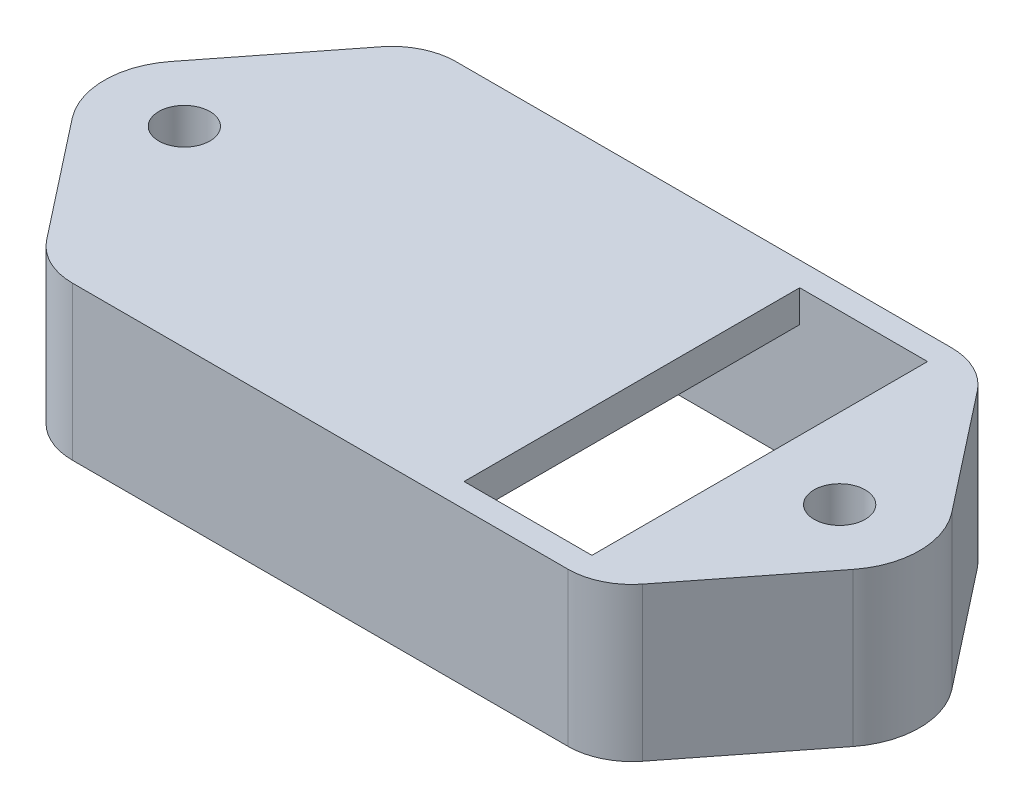
from build123d import *

# Parameters (mm, degrees)
SKETCH1_R           = 0.8
SKETCH1_W           = 15.5
SKETCH1_H           = 10.5
BOSS_EXTRUDE1_DEPTH = 3.8
SKETCH2_R           = 0.8
SKETCH2_W           = 4
SKETCH2_H           = 10.5
BOSS_EXTRUDE2_DEPTH = 1


with BuildPart() as part:
    # Sketch1 → Boss-Extrude1 (new body)
    with BuildSketch(Plane(origin=(0, 0, 0), x_dir=(1, 0, 0), z_dir=(0, 1, 0))):
        with BuildLine():
            Line((-7.75, 6), (7.75, 6))
            ThreePointArc((7.75, 6), (8.62532777, 5.798277313), (9.324082071, 5.233801294))
            Line((9.324082071, 5.233801294), (12.217602589, 1.542251618))
            ThreePointArc((12.217602589, 1.542251618), (12.75, 0), (12.217602589, -1.542251618))
            Line((12.217602589, -1.542251618), (9.324082071, -5.233801294))
            ThreePointArc((9.324082071, -5.233801294), (8.62532777, -5.798277313), (7.75, -6))
            Line((7.75, -6), (-7.75, -6))
            ThreePointArc((-7.75, -6), (-8.62532777, -5.798277313), (-9.324082071, -5.233801294))
            Line((-9.324082071, -5.233801294), (-12.217602589, -1.542251618))
            ThreePointArc((-12.217602589, -1.542251618), (-12.75, 0), (-12.217602589, 1.542251618))
            Line((-12.217602589, 1.542251618), (-9.324082071, 5.233801294))
            ThreePointArc((-9.324082071, 5.233801294), (-8.62532777, 5.798277313), (-7.75, 6))
        make_face()
        with Locations((10.25, 0)):
            Circle(SKETCH1_R, mode=Mode.SUBTRACT)
        with Locations((-10.25, 0)):
            Circle(SKETCH1_R, mode=Mode.SUBTRACT)
        Rectangle(SKETCH1_W, SKETCH1_H, mode=Mode.SUBTRACT)
    extrude(amount=BOSS_EXTRUDE1_DEPTH)

    # Sketch2 → Boss-Extrude2 (add)
    with BuildSketch(Plane(origin=(0, 3.8, 0), x_dir=(1, 0, 0), z_dir=(0, 1, 0))):
        with BuildLine():
            Line((-9.324082071, 5.233801294), (-12.217602589, 1.542251618))
            ThreePointArc((-12.217602589, 1.542251618), (-12.75, 0), (-12.217602589, -1.542251618))
            Line((-12.217602589, -1.542251618), (-9.324082071, -5.233801294))
            ThreePointArc((-9.324082071, -5.233801294), (-8.62532777, -5.798277313), (-7.75, -6))
            Line((-7.75, -6), (7.75, -6))
            ThreePointArc((7.75, -6), (8.62532777, -5.798277313), (9.324082071, -5.233801294))
            Line((9.324082071, -5.233801294), (12.217602589, -1.542251618))
            ThreePointArc((12.217602589, -1.542251618), (12.75, 0), (12.217602589, 1.542251618))
            Line((12.217602589, 1.542251618), (9.324082071, 5.233801294))
            ThreePointArc((9.324082071, 5.233801294), (8.62532777, 5.798277313), (7.75, 6))
            Line((7.75, 6), (-7.75, 6))
            ThreePointArc((-7.75, 6), (-8.62532777, 5.798277313), (-9.324082071, 5.233801294))
        make_face()
        with Locations((10.25, 0)):
            Circle(SKETCH2_R, mode=Mode.SUBTRACT)
        with Locations((-10.25, 0)):
            Circle(SKETCH2_R, mode=Mode.SUBTRACT)
        with Locations((5.75, 0)):
            Rectangle(SKETCH2_W, SKETCH2_H, mode=Mode.SUBTRACT)
    extrude(amount=BOSS_EXTRUDE2_DEPTH)


solid = part.part
